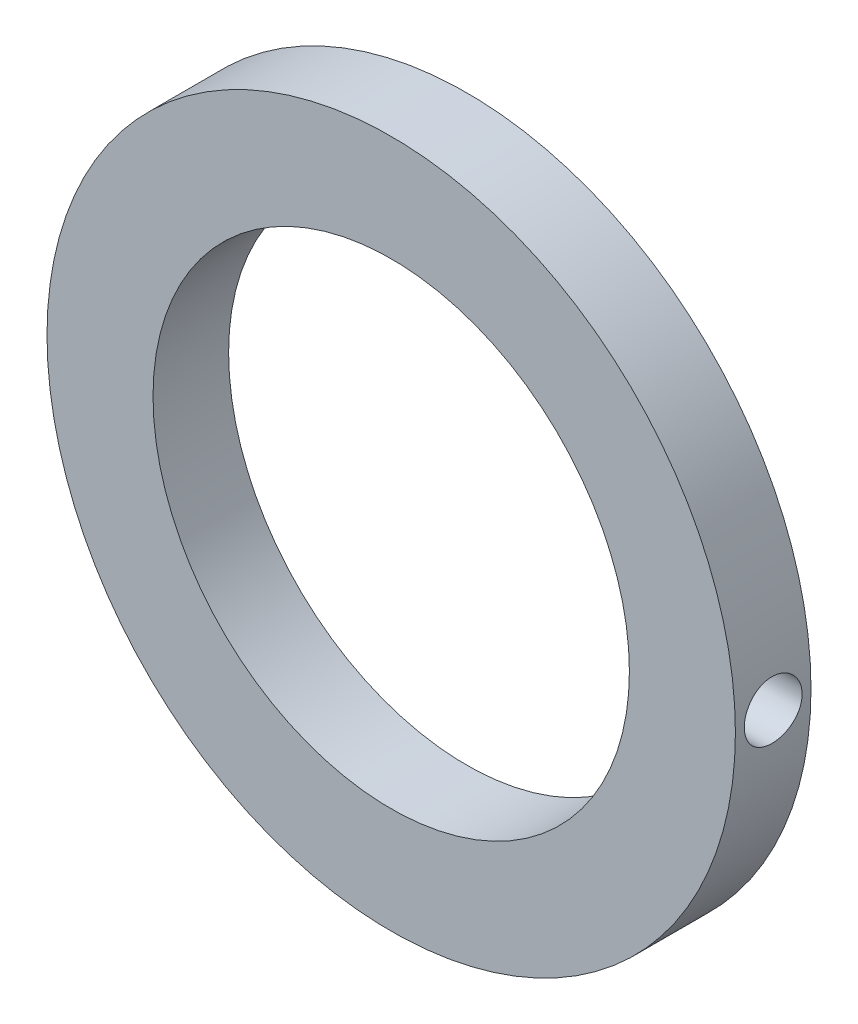
from build123d import *

# Parameters (mm, degrees)
ESBO_O1_R                = 25
ESBO_O1_R_2              = 17.3
RESSALTO_EXTRUS_O1_DEPTH = 5.49
ESBO_O2_W                = 2.1
ESBO_O2_H                = 25


with BuildPart() as part:
    # Esboço1 → Ressalto-extrusão1 (new body)
    with BuildSketch(Plane.XY):
        Circle(ESBO_O1_R)
        Circle(ESBO_O1_R_2, mode=Mode.SUBTRACT)
    extrude(amount=RESSALTO_EXTRUS_O1_DEPTH)

    # Esboço2 → Furo roscado de M5x0.81 (revolve, cut)
    with BuildSketch(Plane(origin=(0, 0, 2.745), x_dir=(0, 0, 1), z_dir=(0, 1, 0))):
        with Locations((1.05, 12.5)):
            Rectangle(ESBO_O2_W, ESBO_O2_H)
    revolve(axis=Axis((-6.35, 0, 2.745), (1, 0, 0)), mode=Mode.SUBTRACT)


solid = part.part
